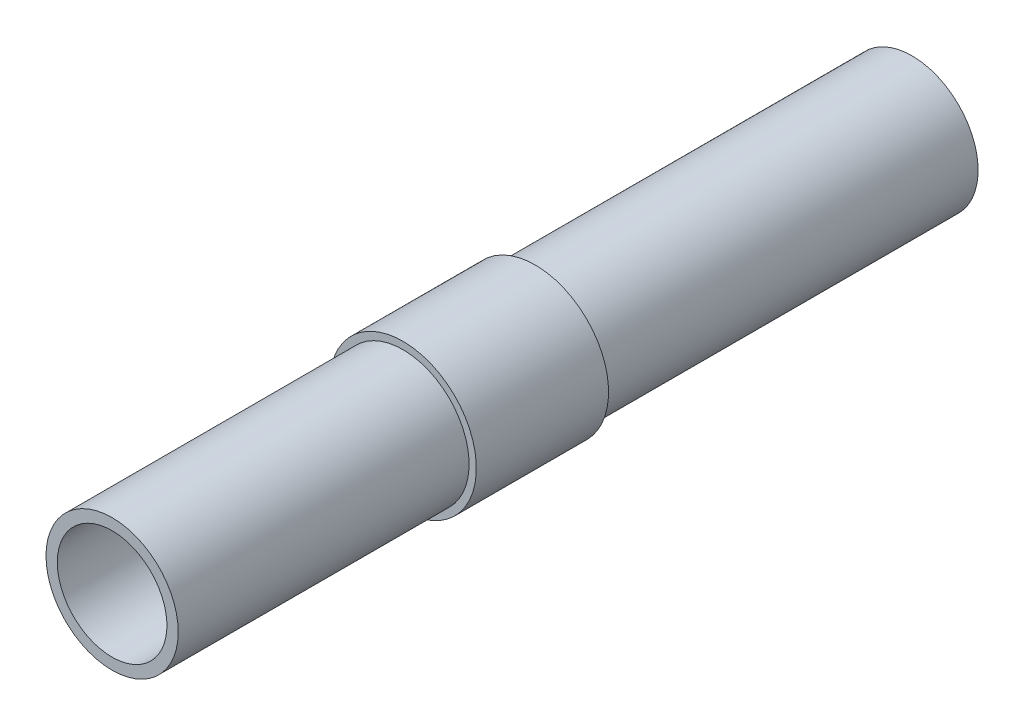
from build123d import *

# Parameters (mm, degrees)
SKETCH1_R           = 11.1
BOSS_EXTRUDE1_DEPTH = 58
SKETCH2_R           = 24.777888598
SKETCH2_R_2         = 10
CUT_EXTRUDE1_DEPTH  = 24
CUT_EXTRUDE2_START  = -44
SKETCH2_2_R         = 24.777888598
SKETCH2_2_R_2       = 10
CUT_EXTRUDE2_DEPTH  = 14
SKETCH4_R           = 10
BOSS_EXTRUDE3_DEPTH = 30
BOSS_EXTRUDE4_START = 45
SKETCH5_R           = 10
BOSS_EXTRUDE4_DEPTH = 45
SKETCH6_R           = 10
CUT_EXTRUDE3_DEPTH  = 12
SKETCH7_R           = 8.287445099
CUT_EXTRUDE4_DEPTH  = 123.014015588


with BuildPart() as part:
    # Sketch1 → Boss-Extrude1 (new body)
    with BuildSketch(Plane.XY):
        Circle(SKETCH1_R)
    extrude(amount=BOSS_EXTRUDE1_DEPTH)

    # Sketch2 → Cut-Extrude1 (cut)
    with BuildSketch(Plane(origin=(0, 0, 0), x_dir=(-1, 0, 0), z_dir=(0, 0, -1))):
        Circle(SKETCH2_R)
        Circle(SKETCH2_R_2, mode=Mode.SUBTRACT)
    extrude(amount=-CUT_EXTRUDE1_DEPTH, mode=Mode.SUBTRACT)

    # Sketch2_2 → Cut-Extrude2 (cut)
    with BuildSketch(Plane(origin=(0, 0, 0), x_dir=(-1, 0, 0), z_dir=(0, 0, -1)).offset(CUT_EXTRUDE2_START)):
        Circle(SKETCH2_2_R)
        Circle(SKETCH2_2_R_2, mode=Mode.SUBTRACT)
    extrude(amount=-CUT_EXTRUDE2_DEPTH, mode=Mode.SUBTRACT)

    # Sketch4 → Boss-Extrude3 (add)
    with BuildSketch(Plane.XY.offset(58)):
        Circle(SKETCH4_R)
    extrude(amount=BOSS_EXTRUDE3_DEPTH)

    # Sketch5 → Boss-Extrude4 (add)
    with BuildSketch(Plane(origin=(0, 0, 0), x_dir=(-1, 0, 0), z_dir=(0, 0, -1)).offset(BOSS_EXTRUDE4_START)):
        Circle(SKETCH5_R)
    extrude(amount=-BOSS_EXTRUDE4_DEPTH)

    # Sketch6 → Cut-Extrude3 (cut)
    with BuildSketch(Plane(origin=(0, 0, -45), x_dir=(-1, 0, 0), z_dir=(0, 0, -1))):
        Circle(SKETCH6_R)
    extrude(amount=-CUT_EXTRUDE3_DEPTH, mode=Mode.SUBTRACT)

    # Sketch7 → Cut-Extrude4 (cut, through all)
    with BuildSketch(Plane(origin=(0, 0, -33), x_dir=(-1, 0, 0), z_dir=(0, 0, -1))):
        Circle(SKETCH7_R)
    extrude(amount=-CUT_EXTRUDE4_DEPTH, mode=Mode.SUBTRACT)


solid = part.part
